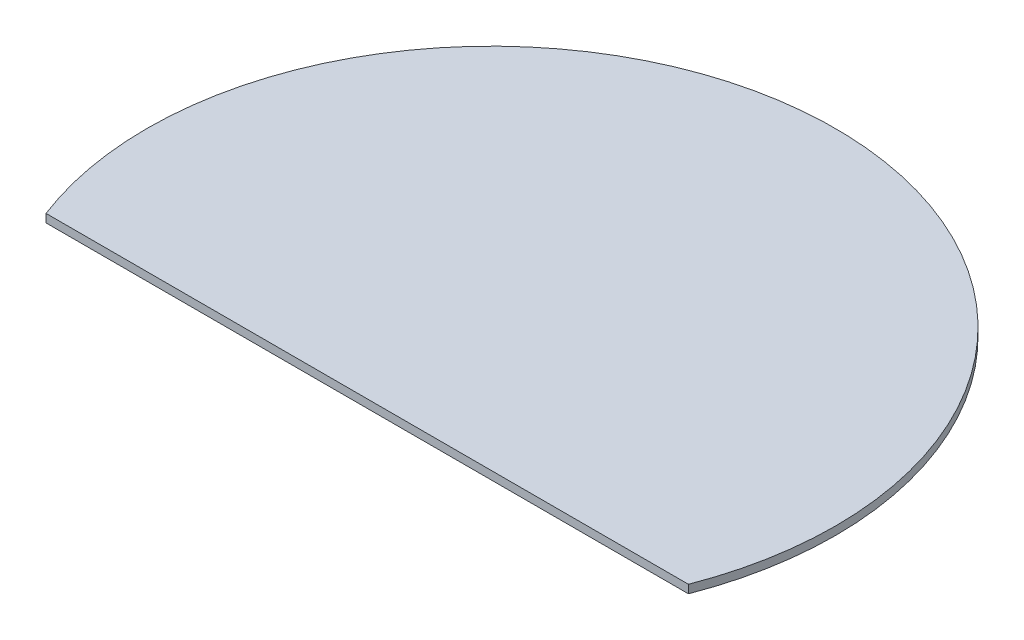
from build123d import *

# Parameters (mm, degrees)
SKETCH2_R           = 125
BOSS_EXTRUDE1_DEPTH = 3
CUT_EXTRUDE1_DEPTH  = 3


with BuildPart() as part:
    # Sketch2 → Boss-Extrude1 (new body)
    with BuildSketch(Plane(origin=(0, 0, 0), x_dir=(1, 0, 0), z_dir=(0, 1, 0))):
        with Locations((-17.80765369, -0.854894607)):
            Circle(SKETCH2_R)
    extrude(amount=BOSS_EXTRUDE1_DEPTH)

    # Sketch3 → Cut-Extrude1 (cut)
    with BuildSketch(Plane.XZ):
        Polygon((-735.289651923, 45.854894607), (-134.426691587, 45.854894607), (98.811384207, 45.854894607), (699.674344543, 45.854894607), (699.674344543, 1247.580815278), (-735.289651923, 1247.580815278), align=None)
    extrude(amount=-CUT_EXTRUDE1_DEPTH, mode=Mode.SUBTRACT)


solid = part.part
